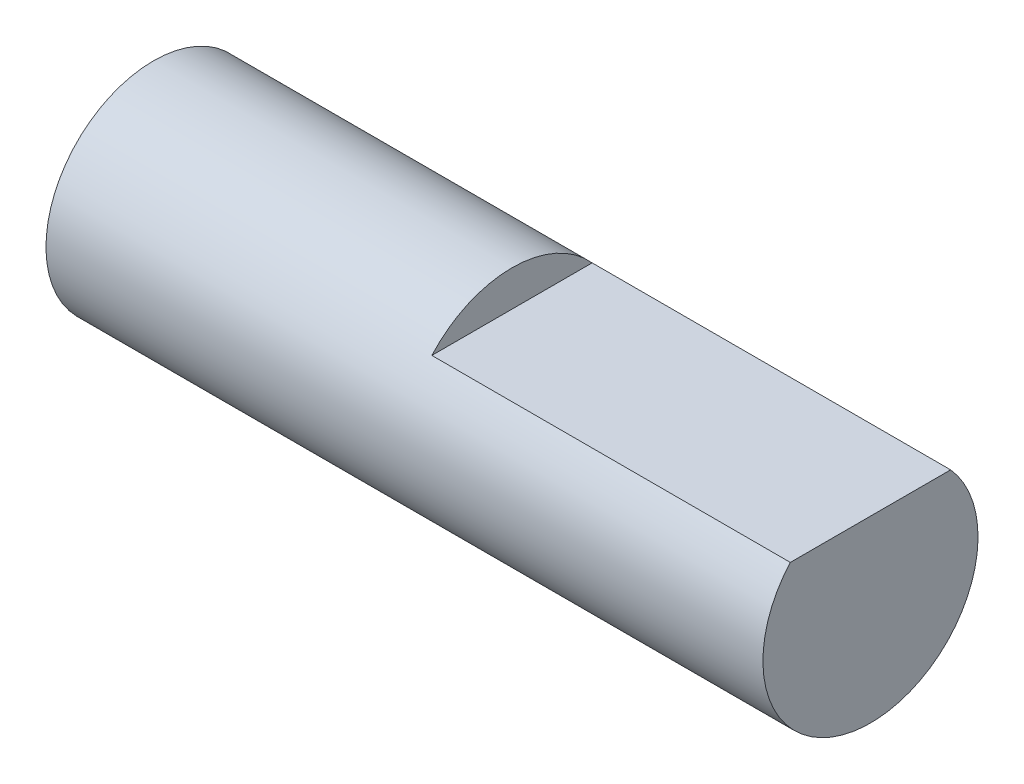
from build123d import *

# Parameters (mm, degrees)
SKETCH2_R           = 3
BOSS_EXTRUDE2_DEPTH = 20
CUT_EXTRUDE1_DEPTH  = 10


with BuildPart() as part:
    # Sketch2 → Boss-Extrude2 (new body)
    with BuildSketch(Plane(origin=(0, 0, 0), x_dir=(0, 0, -1), z_dir=(1, 0, 0))):
        Circle(SKETCH2_R)
    extrude(amount=BOSS_EXTRUDE2_DEPTH)

    # Sketch3 → Cut-Extrude1 (cut)
    with BuildSketch(Plane(origin=(20, 0, 0), x_dir=(0, 0, -1), z_dir=(1, 0, 0))):
        with BuildLine():
            Line((-2.236067977, 2), (2.236067977, 2))
            ThreePointArc((2.236067977, 2), (0, 3), (-2.236067977, 2))
        make_face()
    extrude(amount=-CUT_EXTRUDE1_DEPTH, mode=Mode.SUBTRACT)


solid = part.part
